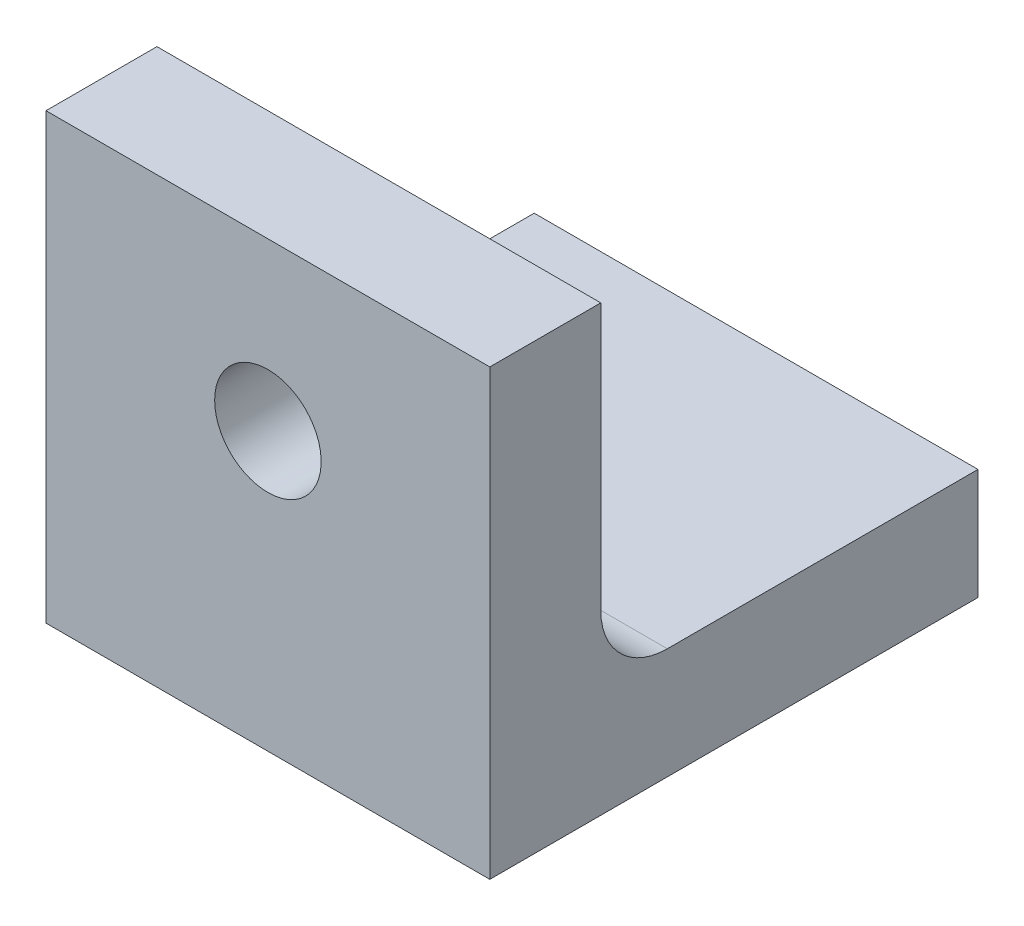
from build123d import *

# Parameters (mm, degrees)
SKETCH1_W                    = 20
SKETCH1_H                    = 5
SKETCH1_H_2                  = 12
BOSS_EXTRUDE1_DEPTH          = 5
SKETCH2_W                    = 20
SKETCH2_H                    = 15
BOSS_EXTRUDE2_DEPTH          = 5
F_5_0_5_DIAMETER_HOLE1_D     = 5
F_5_0_5_DIAMETER_HOLE1_DEPTH = 5
F_4_5_M4_HEAT_SET_D          = 4.8
F_4_5_M4_HEAT_SET_DEPTH      = 5
FILLET1_R                    = 3


with BuildPart() as part:
    # Sketch1 → Boss-Extrude1 (new body)
    with BuildSketch(Plane(origin=(0, 0, 0), x_dir=(1, 0, 0), z_dir=(0, 1, 0))):
        with Locations((0, 8.5)):
            Rectangle(SKETCH1_W, SKETCH1_H)
        Rectangle(SKETCH1_W, SKETCH1_H_2)
        with Locations((0, -8.5)):
            Rectangle(SKETCH1_W, SKETCH1_H)
    extrude(amount=BOSS_EXTRUDE1_DEPTH)

    # Sketch2 → Boss-Extrude2 (add)
    with BuildSketch(Plane.XY.offset(11)):
        with Locations((0, 12.5)):
            Rectangle(SKETCH2_W, SKETCH2_H)
    extrude(amount=-BOSS_EXTRUDE2_DEPTH)

    # Ø5.0 (5) Diameter Hole1
    with Locations(Plane(origin=(0, 5, 0), x_dir=(1, 0, 0), z_dir=(0, 1, 0))):
        with Locations((0, 0)):
            Hole(F_5_0_5_DIAMETER_HOLE1_D / 2, depth=F_5_0_5_DIAMETER_HOLE1_DEPTH)

    # Ø4.5 M4 heat set
    with Locations(Plane(origin=(0, 0, 6), x_dir=(1, 0, 0), z_dir=(0, 0, -1))):
        with Locations((0, -12.5)):
            Hole(F_4_5_M4_HEAT_SET_D / 2, depth=F_4_5_M4_HEAT_SET_DEPTH)

    # Fillet1
    fillet1_edges = [part.edges().sort_by_distance(p)[0] for p in [
        (0, 5, 6),
    ]]
    fillet(fillet1_edges, radius=FILLET1_R)


solid = part.part
